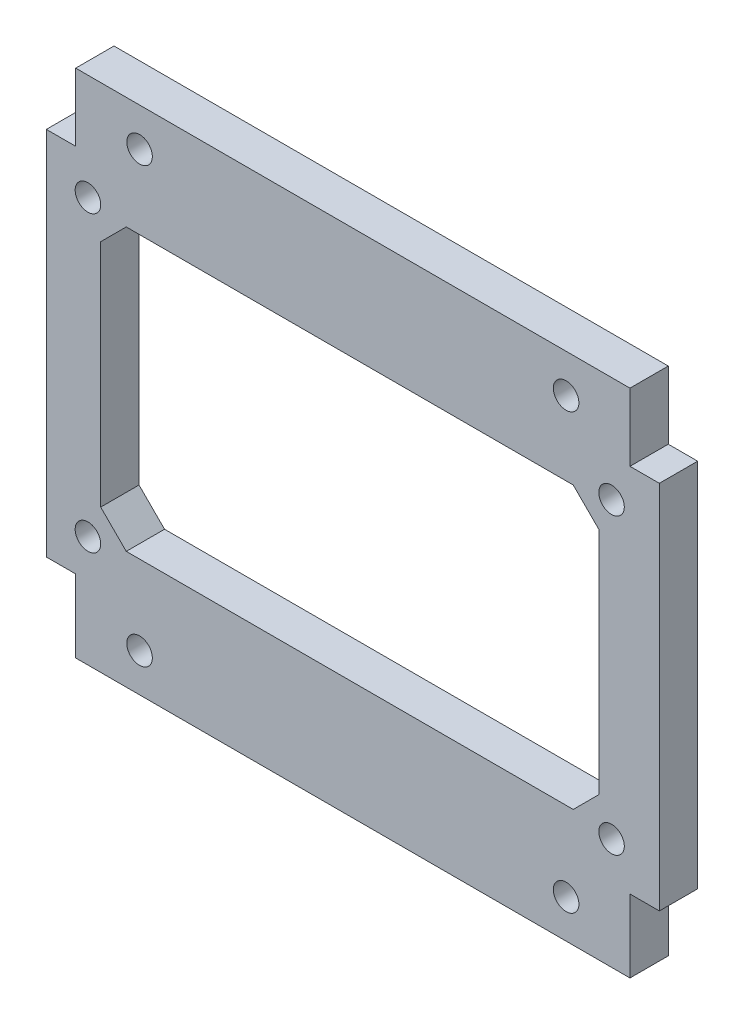
from build123d import *

# Parameters (mm, degrees)
ESBO_O1_W                = 48
ESBO_O1_H                = 40
RESSALTO_EXTRUS_O1_DEPTH = 3
ESBO_O2_R                = 1
CORTE_EXTRUS_O1_DEPTH    = 4
ESBO_O3_W                = 9.79419224
ESBO_O3_H                = 12.19966749
ESBO_O3_H_2              = 11.54056128
ESBO_O3_W_2              = 8.914185242
CORTE_EXTRUS_O2_DEPTH    = 10
CORTE_EXTRUS_O3_DEPTH    = 4
ESBO_O5_R                = 1
ESBO_O5_R_2              = 0.998470841
CORTE_EXTRUS_O4_DEPTH    = 4


with BuildPart() as part:
    # Esboço1 → Ressalto-extrusão1 (new body)
    with BuildSketch(Plane.XY):
        with Locations((26.7, 20)):
            Rectangle(ESBO_O1_W, ESBO_O1_H)
    extrude(amount=RESSALTO_EXTRUS_O1_DEPTH)

    # Esboço2 → Corte-extrusão1 (cut, through all)
    with BuildSketch(Plane.XY.offset(3)):
        with Locations((10, 37)):
            Circle(ESBO_O2_R)
        with Locations((10, 3)):
            Circle(ESBO_O2_R)
        with Locations((43.4, 3)):
            Circle(ESBO_O2_R)
        with Locations((43.4, 37)):
            Circle(ESBO_O2_R)
    extrude(amount=-CORTE_EXTRUS_O1_DEPTH, mode=Mode.SUBTRACT)

    # Esboço3 → Corte-extrusão2 (cut)
    with BuildSketch(Plane.XY.offset(3)):
        with Locations((53.2961889, 40.797789277)):
            Rectangle(ESBO_O3_W, ESBO_O3_H)
        with Locations((53.2961889, -0.072325108)):
            Rectangle(ESBO_O3_W, ESBO_O3_H_2)
        with Locations((0.54181876, -0.072325108)):
            Rectangle(ESBO_O3_W_2, ESBO_O3_H_2)
        with Locations((0.54181876, 40.797789277)):
            Rectangle(ESBO_O3_W_2, ESBO_O3_H)
    extrude(amount=-CORTE_EXTRUS_O2_DEPTH, mode=Mode.SUBTRACT)

    # Esboço4 → Corte-extrusão3 (cut, through all)
    with BuildSketch(Plane.XY.offset(3)):
        Polygon((8.956927741, 31.209698911), (6.956927741, 29.209698911), (6.956927741, 11.209698911), (8.956927741, 9.209698911), (43.956927741, 9.209698911), (45.956927741, 11.209698911), (45.956927741, 29.209698911), (43.956927741, 31.209698911), align=None)
    extrude(amount=-CORTE_EXTRUS_O3_DEPTH, mode=Mode.SUBTRACT)

    # Esboço5 → Corte-extrusão4 (cut, through all)
    with BuildSketch(Plane.XY.offset(3)):
        with Locations((5.956927741, 31.709698911)):
            Circle(ESBO_O5_R)
        with Locations((46.956927741, 31.709698911)):
            Circle(ESBO_O5_R_2)
        with Locations((46.956927741, 8.709698911)):
            Circle(ESBO_O5_R)
        with Locations((5.956927741, 8.709698911)):
            Circle(ESBO_O5_R)
    extrude(amount=-CORTE_EXTRUS_O4_DEPTH, mode=Mode.SUBTRACT)


solid = part.part
